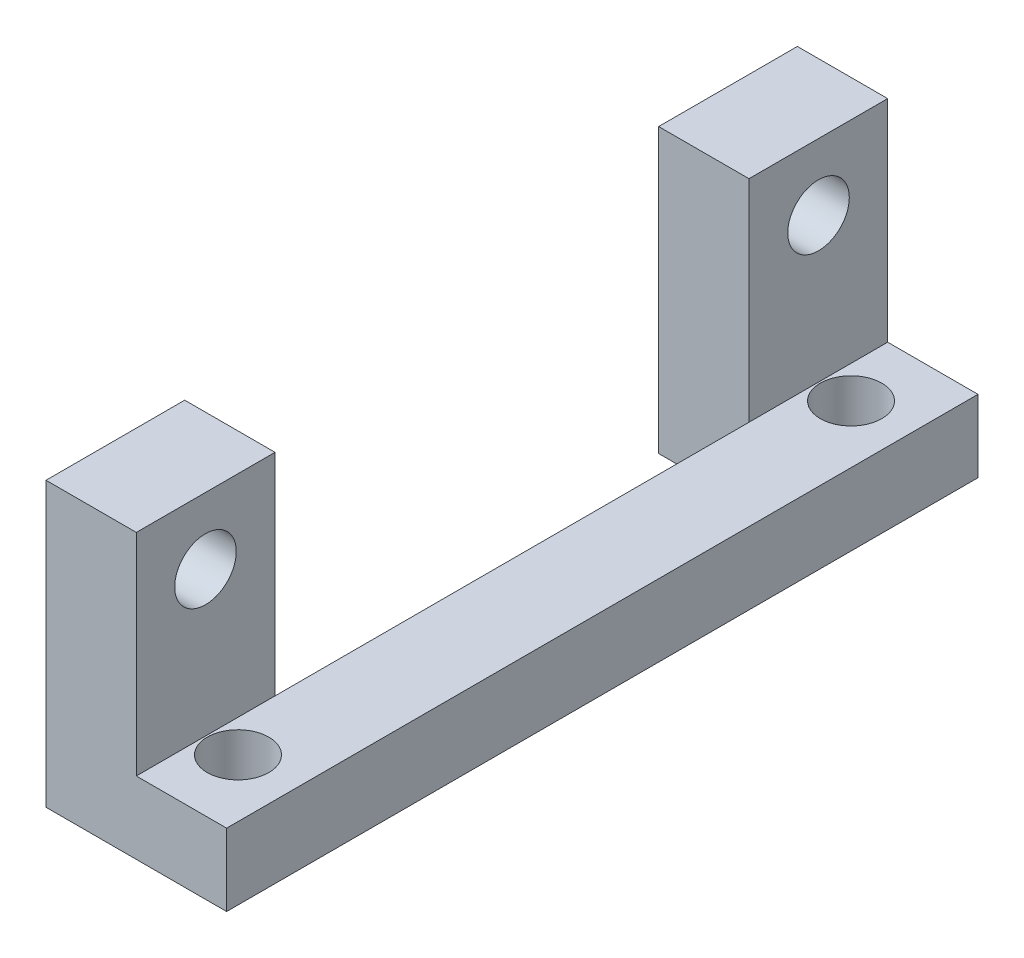
from build123d import *

# Parameters (mm, degrees)
BOSS_EXTRUDE1_DEPTH       = 16.51
CUT_EXTRUDE1_REACH        = 14.446
SKETCH2_W                 = 3.96875
SKETCH2_H                 = 20.828
F_6_32_TAPPED_HOLE1_D     = 2.7051
F_6_32_TAPPED_HOLE1_DEPTH = 3.96875
F_6_32_TAPPED_HOLE2_D     = 2.7051
F_6_32_TAPPED_HOLE2_DEPTH = 3.175


with BuildPart() as part:
    # Sketch1 → Boss-Extrude1 (new body, symmetric)
    with BuildSketch(Plane.XY):
        Polygon((0, 12.446), (0, 0), (7.9375, 0), (7.9375, 3.175), (3.96875, 3.175), (3.96875, 12.446), align=None)
    extrude(amount=BOSS_EXTRUDE1_DEPTH, both=True)

    # Sketch2 → Cut-Extrude1 (cut, up to next)
    with BuildSketch(Plane(origin=(0, 12.446, 0), x_dir=(1, 0, 0), z_dir=(0, 1, 0)), mode=Mode.PRIVATE) as cut_extrude1_sk1:
        with Locations((1.984375, 0)):
            Rectangle(SKETCH2_W, SKETCH2_H)
    cut_extrude1_tool1 = extrude(cut_extrude1_sk1.sketch, amount=-CUT_EXTRUDE1_REACH, mode=Mode.PRIVATE) & part.part
    add(cut_extrude1_tool1.solids().sort_by_distance((1.984375, 12.446, 0))[0], mode=Mode.SUBTRACT)

    # #6-32 Tapped Hole1
    with Locations(Plane(origin=(3.96875, 0, 0), x_dir=(0, 0, -1), z_dir=(1, 0, 0))):
        with Locations((-13.470384182, 9.525), (13.470384182, 9.525)):
            Hole(F_6_32_TAPPED_HOLE1_D / 2, depth=F_6_32_TAPPED_HOLE1_DEPTH)

    # #6-32 Tapped Hole2
    with Locations(Plane.XZ):
        with Locations((5.3975, 13.470384182), (5.3975, -13.470384182)):
            Hole(F_6_32_TAPPED_HOLE2_D / 2, depth=F_6_32_TAPPED_HOLE2_DEPTH)


solid = part.part
